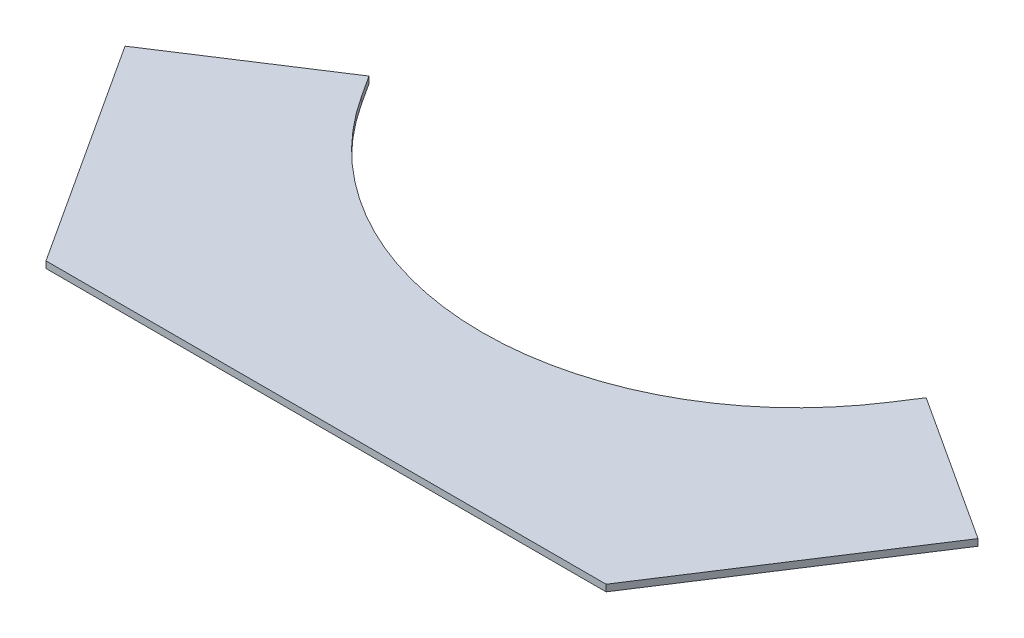
from build123d import *

# Parameters (mm, degrees)
BOSS_EXTRUDE1_DEPTH = 6.35


with BuildPart() as part:
    # Sketch1 → Boss-Extrude1 (new body)
    with BuildSketch(Plane(origin=(0, 0, 0), x_dir=(1, 0, 0), z_dir=(0, 1, 0))):
        with BuildLine():
            Line((0, 0), (534.9068, 0))
            Line((534.9068, 0), (674.758176597, 215.352234963))
            Line((674.758176597, 215.352234963), (533.506092595, 307.082410869))
            Line((533.506092595, 307.082410869), (519.89011672, 286.11564667))
            ThreePointArc((519.89011672, 286.11564667), (267.4534, 149.053692529), (15.01668328, 286.11564667))
            Line((15.01668328, 286.11564667), (1.400707405, 307.082410869))
            Line((1.400707405, 307.082410869), (-139.851376597, 215.352234963))
            Line((-139.851376597, 215.352234963), (0, 0))
        make_face()
    extrude(amount=BOSS_EXTRUDE1_DEPTH)


solid = part.part
